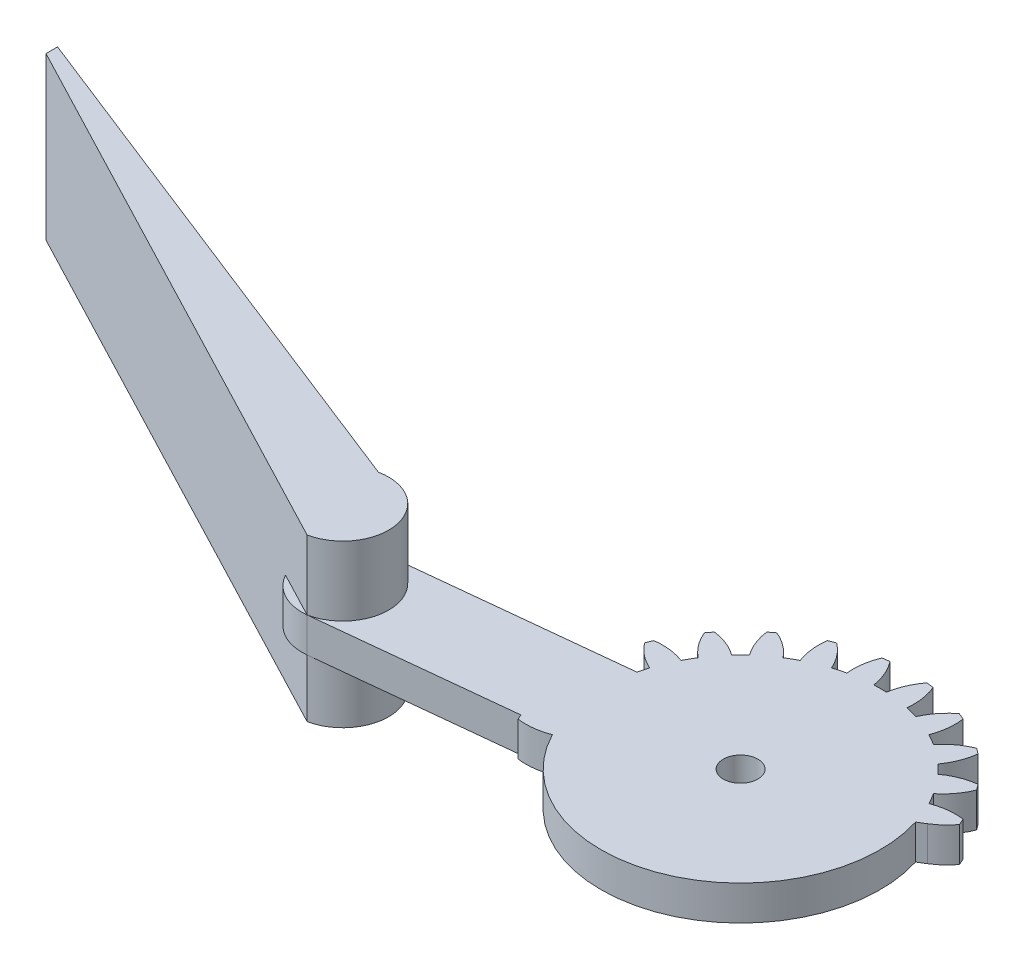
from build123d import *
from build123d.topology import SkipClean

# Parameters (mm, degrees)
SKETCH1_R                = 1.5
BOSS_EXTRUDE1_DEPTH      = 3
BOSS_EXTRUDE2_START      = -3
SKETCH3_R                = 1.5
BOSS_EXTRUDE2_DEPTH      = 3
CUT_EXTRUDE1_START       = -3
CUT_EXTRUDE1_DEPTH       = 3
BOSS_EXTRUDE3_DEPTH      = 6
BOSS_EXTRUDE3_DEPTH_BACK = 8


with BuildPart() as part:
    # Sketch1 → Boss-Extrude1 (new body)
    with BuildSketch(Plane(origin=(0, 0, 0), x_dir=(1, 0, 0), z_dir=(0, 1, 0))):
        with BuildLine():
            Line((20.643657446, 4), (2.081641936, 4))
            ThreePointArc((2.081641936, 4), (2.861028333, 4.588201733), (3.521749436, 5.30713988))
            ThreePointArc((3.521749436, 5.30713988), (3.405395609, 5.596745198), (3.282888305, 5.883801663))
            ThreePointArc((3.282888305, 5.883801663), (1.93527598, 5.894040025), (0.627094961, 5.57027124))
            ThreePointArc((0.627094961, 5.57027124), (0.366286148, 6.046375), (0.084372603, 6.510293938))
            ThreePointArc((0.084372603, 6.510293938), (1.018855105, 7.48132754), (1.683794586, 8.65351323))
            ThreePointArc((1.683794586, 8.65351323), (1.496450048, 8.903135899), (1.303821399, 9.148703928))
            ThreePointArc((1.303821399, 9.148703928), (-0.000522033, 8.809805691), (-1.180330337, 8.158486898))
            ThreePointArc((-1.180330337, 8.158486898), (-1.555477026, 8.550865528), (-1.947855656, 8.926012217))
            ThreePointArc((-1.947855656, 8.926012217), (-1.296536862, 10.105820521), (-0.957638625, 11.410163953))
            ThreePointArc((-0.957638625, 11.410163953), (-1.203206655, 11.602792602), (-1.452829324, 11.79013714))
            ThreePointArc((-1.452829324, 11.79013714), (-2.625015014, 11.125197659), (-3.596048616, 10.190715157))
            ThreePointArc((-3.596048616, 10.190715157), (-4.059967554, 10.472628702), (-4.536071314, 10.733437515))
            ThreePointArc((-4.536071314, 10.733437515), (-4.212302529, 12.041618533), (-4.222540891, 13.389230859))
            ThreePointArc((-4.222540891, 13.389230859), (-4.509597355, 13.511738163), (-4.799202674, 13.62809199))
            ThreePointArc((-4.799202674, 13.62809199), (-5.759348103, 12.682425791), (-6.455432668, 11.528463019))
            ThreePointArc((-6.455432668, 11.528463019), (-6.976508546, 11.680699536), (-7.503891752, 11.809396783))
            ThreePointArc((-7.503891752, 11.809396783), (-7.529737283, 13.156800143), (-7.888414517, 14.455843809))
            ThreePointArc((-7.888414517, 14.455843809), (-8.197396993, 14.499881098), (-8.507248835, 14.537314892))
            ThreePointArc((-8.507248835, 14.537314892), (-9.18992168, 13.375367565), (-9.563620196, 12.080565177))
            ThreePointArc((-9.563620196, 12.080565177), (-10.106342554, 12.09275), (-10.649064912, 12.080565177))
            ThreePointArc((-10.649064912, 12.080565177), (-11.022763428, 13.375367565), (-11.705436272, 14.537314892))
            ThreePointArc((-11.705436272, 14.537314892), (-12.015288115, 14.499881098), (-12.324270591, 14.455843809))
            ThreePointArc((-12.324270591, 14.455843809), (-12.682947825, 13.156800143), (-12.708793355, 11.809396783))
            ThreePointArc((-12.708793355, 11.809396783), (-13.236176561, 11.680699536), (-13.757252439, 11.528463019))
            ThreePointArc((-13.757252439, 11.528463019), (-14.453337005, 12.682425791), (-15.413482434, 13.62809199))
            ThreePointArc((-15.413482434, 13.62809199), (-15.703087752, 13.511738163), (-15.990144217, 13.389230859))
            ThreePointArc((-15.990144217, 13.389230859), (-16.000382579, 12.041618533), (-15.676613793, 10.733437515))
            ThreePointArc((-15.676613793, 10.733437515), (-16.152717554, 10.472628702), (-16.616636492, 10.190715157))
            ThreePointArc((-16.616636492, 10.190715157), (-17.587670094, 11.125197659), (-18.759855783, 11.79013714))
            ThreePointArc((-18.759855783, 11.79013714), (-19.009478453, 11.602792602), (-19.255046482, 11.410163953))
            ThreePointArc((-19.255046482, 11.410163953), (-18.916148245, 10.105820521), (-18.264829452, 8.926012217))
            ThreePointArc((-18.264829452, 8.926012217), (-18.657208082, 8.550865528), (-19.032354771, 8.158486898))
            ThreePointArc((-19.032354771, 8.158486898), (-20.212163074, 8.809805691), (-21.516506507, 9.148703928))
            ThreePointArc((-21.516506507, 9.148703928), (-21.709135156, 8.903135899), (-21.896479694, 8.65351323))
            ThreePointArc((-21.896479694, 8.65351323), (-21.231540213, 7.48132754), (-20.297057711, 6.510293938))
            ThreePointArc((-20.297057711, 6.510293938), (-20.578971255, 6.046375), (-20.839780068, 5.57027124))
            ThreePointArc((-20.839780068, 5.57027124), (-22.147961087, 5.894040025), (-23.495573413, 5.883801663))
            ThreePointArc((-23.495573413, 5.883801663), (-23.618080717, 5.596745198), (-23.734434544, 5.30713988))
            ThreePointArc((-23.734434544, 5.30713988), (-22.788768345, 4.346994451), (-21.634805572, 3.650909885))
            ThreePointArc((-21.634805572, 3.650909885), (-21.78704209, 3.129834008), (-21.915739337, 2.602450802))
            ThreePointArc((-21.915739337, 2.602450802), (-23.263142697, 2.576605271), (-24.562186363, 2.217928037))
            ThreePointArc((-24.562186363, 2.217928037), (-24.606223651, 1.908945561), (-24.643657446, 1.599093719))
            ThreePointArc((-24.643657446, 1.599093719), (-23.481710119, 0.916420874), (-22.186907731, 0.542722358))
            ThreePointArc((-22.186907731, 0.542722358), (-22.199092554, 0), (-22.186907731, -0.542722358))
            ThreePointArc((-22.186907731, -0.542722358), (-23.481710119, -0.916420874), (-24.643657446, -1.599093719))
            ThreePointArc((-24.643657446, -1.599093719), (-24.606223651, -1.908945561), (-24.562186363, -2.217928037))
            ThreePointArc((-24.562186363, -2.217928037), (-23.263142697, -2.576605271), (-21.915739337, -2.602450802))
            ThreePointArc((-21.915739337, -2.602450802), (-21.78704209, -3.129834008), (-21.634805572, -3.650909885))
            ThreePointArc((-21.634805572, -3.650909885), (-22.788768345, -4.346994451), (-23.734434544, -5.30713988))
            ThreePointArc((-23.734434544, -5.30713988), (-23.618080717, -5.596745198), (-23.495573413, -5.883801663))
            ThreePointArc((-23.495573413, -5.883801663), (-22.147961087, -5.894040025), (-20.839780068, -5.57027124))
            ThreePointArc((-20.839780068, -5.57027124), (-20.578971255, -6.046375), (-20.297057711, -6.510293938))
            ThreePointArc((-20.297057711, -6.510293938), (-21.231540213, -7.48132754), (-21.896479694, -8.65351323))
            ThreePointArc((-21.896479694, -8.65351323), (-21.709135156, -8.903135899), (-21.516506507, -9.148703928))
            ThreePointArc((-21.516506507, -9.148703928), (-20.212163074, -8.809805691), (-19.032354771, -8.158486898))
            ThreePointArc((-19.032354771, -8.158486898), (-18.657208082, -8.550865528), (-18.264829452, -8.926012217))
            ThreePointArc((-18.264829452, -8.926012217), (-18.916148245, -10.105820521), (-19.255046482, -11.410163953))
            ThreePointArc((-19.255046482, -11.410163953), (-19.009478453, -11.602792602), (-18.759855783, -11.79013714))
            ThreePointArc((-18.759855783, -11.79013714), (-17.587670094, -11.125197659), (-16.616636492, -10.190715157))
            ThreePointArc((-16.616636492, -10.190715157), (-16.152717554, -10.472628702), (-15.676613793, -10.733437515))
            ThreePointArc((-15.676613793, -10.733437515), (-16.000382579, -12.041618533), (-15.990144217, -13.389230859))
            ThreePointArc((-15.990144217, -13.389230859), (-15.703087752, -13.511738163), (-15.413482434, -13.62809199))
            ThreePointArc((-15.413482434, -13.62809199), (-14.453337005, -12.682425791), (-13.757252439, -11.528463019))
            ThreePointArc((-13.757252439, -11.528463019), (-13.236176561, -11.680699536), (-12.708793355, -11.809396783))
            ThreePointArc((-12.708793355, -11.809396783), (-12.682947825, -13.156800143), (-12.324270591, -14.455843809))
            ThreePointArc((-12.324270591, -14.455843809), (-12.015288115, -14.499881098), (-11.705436272, -14.537314892))
            ThreePointArc((-11.705436272, -14.537314892), (-11.022763428, -13.375367565), (-10.649064912, -12.080565177))
            ThreePointArc((-10.649064912, -12.080565177), (-10.106342554, -12.09275), (-9.563620196, -12.080565177))
            ThreePointArc((-9.563620196, -12.080565177), (-9.18992168, -13.375367565), (-8.507248835, -14.537314892))
            ThreePointArc((-8.507248835, -14.537314892), (-8.197396993, -14.499881098), (-7.888414517, -14.455843809))
            ThreePointArc((-7.888414517, -14.455843809), (-7.529737283, -13.156800143), (-7.503891752, -11.809396783))
            ThreePointArc((-7.503891752, -11.809396783), (-6.976508546, -11.680699536), (-6.455432668, -11.528463019))
            ThreePointArc((-6.455432668, -11.528463019), (-5.759348103, -12.682425791), (-4.799202674, -13.62809199))
            ThreePointArc((-4.799202674, -13.62809199), (-4.509597355, -13.511738163), (-4.222540891, -13.389230859))
            ThreePointArc((-4.222540891, -13.389230859), (-4.212302529, -12.041618533), (-4.536071314, -10.733437515))
            ThreePointArc((-4.536071314, -10.733437515), (-4.059967554, -10.472628702), (-3.596048616, -10.190715157))
            ThreePointArc((-3.596048616, -10.190715157), (-2.625015014, -11.125197659), (-1.452829324, -11.79013714))
            ThreePointArc((-1.452829324, -11.79013714), (-1.203206655, -11.602792602), (-0.957638625, -11.410163953))
            ThreePointArc((-0.957638625, -11.410163953), (-1.296536862, -10.105820521), (-1.947855656, -8.926012217))
            ThreePointArc((-1.947855656, -8.926012217), (-1.555477026, -8.550865528), (-1.180330337, -8.158486898))
            ThreePointArc((-1.180330337, -8.158486898), (-0.000522033, -8.809805691), (1.303821399, -9.148703928))
            ThreePointArc((1.303821399, -9.148703928), (1.496450048, -8.903135899), (1.683794586, -8.65351323))
            ThreePointArc((1.683794586, -8.65351323), (1.018855105, -7.48132754), (0.084372603, -6.510293938))
            ThreePointArc((0.084372603, -6.510293938), (0.366286148, -6.046375), (0.627094961, -5.57027124))
            ThreePointArc((0.627094961, -5.57027124), (1.93527598, -5.894040025), (3.282888305, -5.883801663))
            ThreePointArc((3.282888305, -5.883801663), (3.405395609, -5.596745198), (3.521749436, -5.30713988))
            ThreePointArc((3.521749436, -5.30713988), (2.861028333, -4.588201733), (2.081641936, -4))
            Line((2.081641936, -4), (20.643657446, -4))
            ThreePointArc((20.643657446, -4), (24.643657446, 0), (20.643657446, 4))
        make_face()
        with Locations((-10.106342554, 0)):
            Circle(SKETCH1_R, mode=Mode.SUBTRACT)
        with Locations((20.643657446, 0)):
            Circle(SKETCH1_R, mode=Mode.SUBTRACT)
    extrude(amount=BOSS_EXTRUDE1_DEPTH)

    # Sketch3 → Boss-Extrude2 (add)
    with BuildSketch(Plane(origin=(0, 3, 0), x_dir=(1, 0, 0), z_dir=(0, 1, 0)).offset(BOSS_EXTRUDE2_START)):
        with BuildLine():
            Line((-10.524456407, 3.978087581), (-41.274456407, 0.746132347))
            ThreePointArc((-41.274456407, 0.746132347), (-44.834430135, -3.650069087), (-40.438228701, -7.210042816))
            Line((-40.438228701, -7.210042816), (-9.688228701, -3.978087581))
            ThreePointArc((-9.688228701, -3.978087581), (-6.128254972, 0.418113853), (-10.524456407, 3.978087581))
        make_face()
        with Locations((-10.106342554, 0)):
            Circle(SKETCH3_R, mode=Mode.SUBTRACT)
        with Locations((-40.856342554, -3.231955234)):
            Circle(SKETCH3_R, mode=Mode.SUBTRACT)
    extrude(amount=BOSS_EXTRUDE2_DEPTH)

    # Sketch4 → Cut-Extrude1 (cut)
    with SkipClean():  # the faces are left unmerged after this step: merging them gives an invalid solid
        with BuildSketch(Plane(origin=(0, 3, 0), x_dir=(1, 0, 0), z_dir=(0, 1, 0)).offset(CUT_EXTRUDE1_START)):
            with BuildLine():
                ThreePointArc((20.643657446, -4), (24.643657446, 0), (20.643657446, 4))
                Line((20.643657446, 4), (2.081641936, 4))
                Line((2.081641936, 4), (1.43808022, 3.600125745))
                ThreePointArc((1.43808022, 3.600125745), (1.939395696, -1.065266441), (0.627094961, -5.57027124))
                ThreePointArc((0.627094961, -5.57027124), (1.93527598, -5.894040025), (3.282888305, -5.883801663))
                ThreePointArc((3.282888305, -5.883801663), (3.405395609, -5.596745198), (3.521749436, -5.30713988))
                ThreePointArc((3.521749436, -5.30713988), (2.861028333, -4.588201733), (2.081641936, -4))
                Line((2.081641936, -4), (20.643657446, -4))
            make_face()
            with BuildLine():
                ThreePointArc((1.683794586, -8.65351323), (1.018855105, -7.48132754), (0.084372603, -6.510293938))
                ThreePointArc((0.084372603, -6.510293938), (-0.512518948, -7.361599771), (-1.180330337, -8.158486898))
                ThreePointArc((-1.180330337, -8.158486898), (-0.000522033, -8.809805691), (1.303821399, -9.148703928))
                ThreePointArc((1.303821399, -9.148703928), (1.496450048, -8.903135899), (1.683794586, -8.65351323))
            make_face()
            with BuildLine():
                ThreePointArc((-0.957638625, -11.410163953), (-1.296536862, -10.105820521), (-1.947855656, -8.926012217))
                ThreePointArc((-1.947855656, -8.926012217), (-2.744742783, -9.593823606), (-3.596048616, -10.190715157))
                ThreePointArc((-3.596048616, -10.190715157), (-2.625015014, -11.125197659), (-1.452829324, -11.79013714))
                ThreePointArc((-1.452829324, -11.79013714), (-1.203206655, -11.602792602), (-0.957638625, -11.410163953))
            make_face()
            with BuildLine():
                ThreePointArc((-4.222540891, -13.389230859), (-4.212302529, -12.041618533), (-4.536071314, -10.733437515))
                ThreePointArc((-4.536071314, -10.733437515), (-5.478647477, -11.172244217), (-6.455432668, -11.528463019))
                ThreePointArc((-6.455432668, -11.528463019), (-5.759348103, -12.682425791), (-4.799202674, -13.62809199))
                ThreePointArc((-4.799202674, -13.62809199), (-4.509597355, -13.511738163), (-4.222540891, -13.389230859))
            make_face()
            with BuildLine():
                ThreePointArc((-7.888414517, -14.455843809), (-7.529737283, -13.156800143), (-7.503891752, -11.809396783))
                ThreePointArc((-7.503891752, -11.809396783), (-8.527921943, -11.989294847), (-9.563620196, -12.080565177))
                ThreePointArc((-9.563620196, -12.080565177), (-9.18992168, -13.375367565), (-8.507248835, -14.537314892))
                ThreePointArc((-8.507248835, -14.537314892), (-8.197396993, -14.499881098), (-7.888414517, -14.455843809))
            make_face()
            with BuildLine():
                ThreePointArc((-11.705436272, -14.537314892), (-11.022763428, -13.375367565), (-10.649064912, -12.080565177))
                ThreePointArc((-10.649064912, -12.080565177), (-11.684763165, -11.989294847), (-12.708793355, -11.809396783))
                ThreePointArc((-12.708793355, -11.809396783), (-12.682947825, -13.156800143), (-12.324270591, -14.455843809))
                ThreePointArc((-12.324270591, -14.455843809), (-12.015288115, -14.499881098), (-11.705436272, -14.537314892))
            make_face()
            with BuildLine():
                ThreePointArc((-15.413482434, -13.62809199), (-14.453337005, -12.682425791), (-13.757252439, -11.528463019))
                ThreePointArc((-13.757252439, -11.528463019), (-14.734037631, -11.172244217), (-15.676613793, -10.733437515))
                ThreePointArc((-15.676613793, -10.733437515), (-16.000382579, -12.041618533), (-15.990144217, -13.389230859))
                ThreePointArc((-15.990144217, -13.389230859), (-15.703087752, -13.511738163), (-15.413482434, -13.62809199))
            make_face()
            with BuildLine():
                ThreePointArc((-18.759855783, -11.79013714), (-17.587670094, -11.125197659), (-16.616636492, -10.190715157))
                ThreePointArc((-16.616636492, -10.190715157), (-17.467942324, -9.593823606), (-18.264829452, -8.926012217))
                ThreePointArc((-18.264829452, -8.926012217), (-18.916148245, -10.105820521), (-19.255046482, -11.410163953))
                ThreePointArc((-19.255046482, -11.410163953), (-19.009478453, -11.602792602), (-18.759855783, -11.79013714))
            make_face()
            with BuildLine():
                ThreePointArc((-21.516506507, -9.148703928), (-20.212163074, -8.809805691), (-19.032354771, -8.158486898))
                ThreePointArc((-19.032354771, -8.158486898), (-19.70016616, -7.361599771), (-20.297057711, -6.510293938))
                ThreePointArc((-20.297057711, -6.510293938), (-21.231540213, -7.48132754), (-21.896479694, -8.65351323))
                ThreePointArc((-21.896479694, -8.65351323), (-21.709135156, -8.903135899), (-21.516506507, -9.148703928))
            make_face()
        extrude(amount=CUT_EXTRUDE1_DEPTH, mode=Mode.SUBTRACT)

    # Sketch5 → Boss-Extrude3 (add, two sides: drawn at the far end of the back side and taken through both)
    with SkipClean():  # the faces are left unmerged after this step: merging them gives an invalid solid
        with BuildSketch(Plane(origin=(0, 3, 0), x_dir=(1, 0, 0), z_dir=(0, 1, 0)).offset(-BOSS_EXTRUDE3_DEPTH_BACK)):
            with BuildLine():
                Line((-42.053620407, 0.58465658), (-87.849323809, 18.590837409))
                Line((-87.849323809, 18.590837409), (-87.849323809, 17.589536845))
                Line((-87.849323809, 17.589536845), (-40.438228701, -7.210042816))
                ThreePointArc((-40.438228701, -7.210042816), (-37.348574856, -2.504997265), (-42.053620407, 0.58465658))
            make_face()
        extrude(amount=BOSS_EXTRUDE3_DEPTH + BOSS_EXTRUDE3_DEPTH_BACK)


solid = part.part
